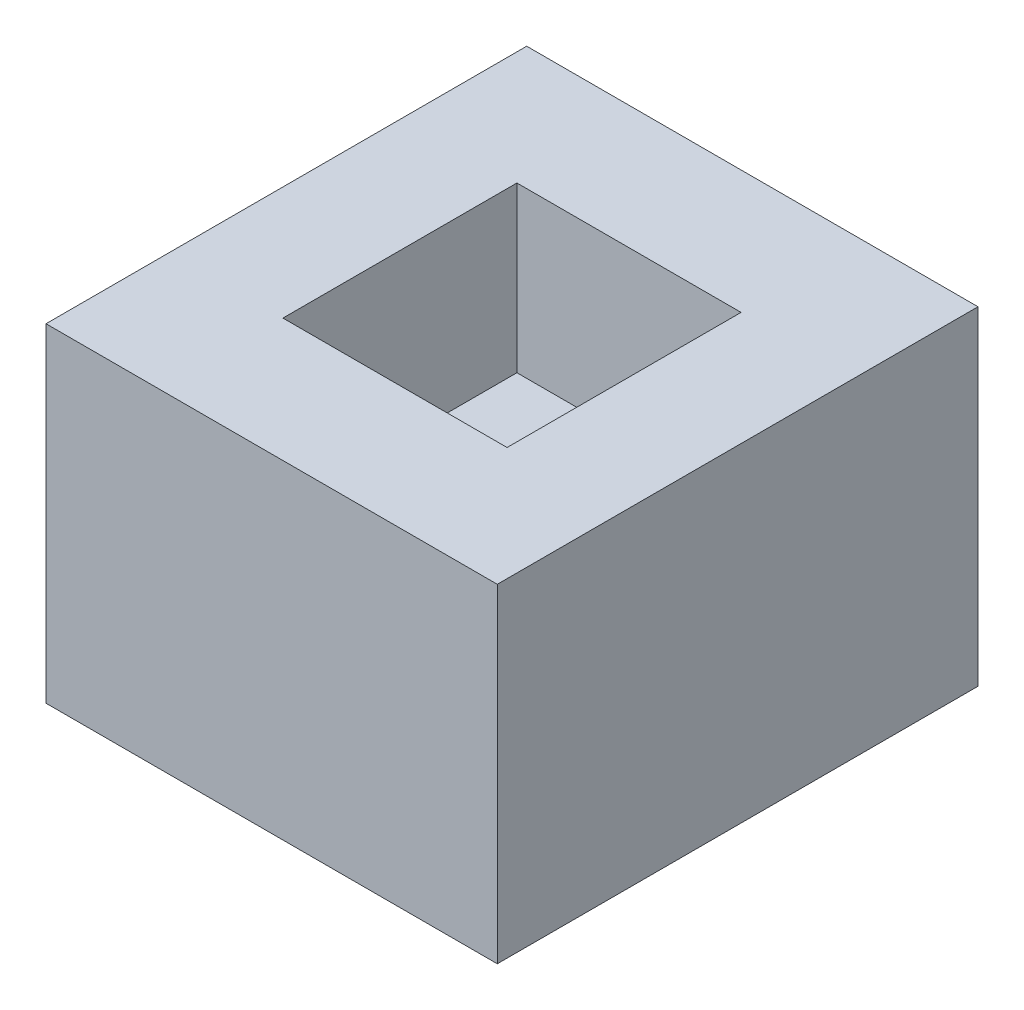
from build123d import *

# Parameters (mm, degrees)
SKETCH1_W           = 109.845286248
SKETCH1_H           = 117.004476482
BOSS_EXTRUDE1_DEPTH = 80
SKETCH2_W           = 54.561390782
SKETCH2_H           = 56.953727806
CUT_EXTRUDE1_DEPTH  = 40


with BuildPart() as part:
    # Sketch1 → Boss-Extrude1 (new body)
    with BuildSketch(Plane(origin=(0, 0, 0), x_dir=(1, 0, 0), z_dir=(0, 1, 0))):
        Rectangle(SKETCH1_W, SKETCH1_H)
    extrude(amount=BOSS_EXTRUDE1_DEPTH)

    # Sketch2 → Cut-Extrude1 (cut)
    with BuildSketch(Plane(origin=(0, 80, 0), x_dir=(1, 0, 0), z_dir=(0, 1, 0))):
        Rectangle(SKETCH2_W, SKETCH2_H)
    extrude(amount=-CUT_EXTRUDE1_DEPTH, mode=Mode.SUBTRACT)


solid = part.part
